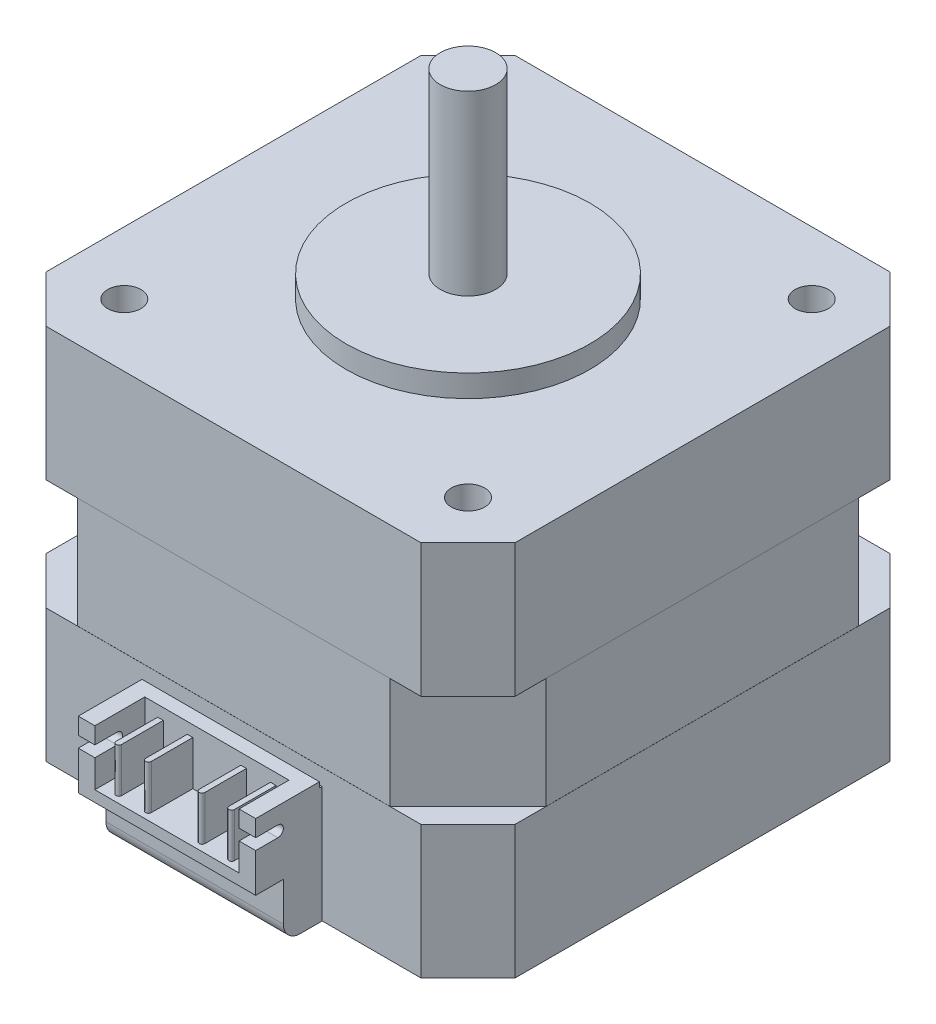
from build123d import *

# Parameters (mm, degrees)
SKETCH1_W               = 42.3
SKETCH1_H               = 42.3
BOSS_EXTRUDE1_DEPTH     = 34
SKETCH2_R               = 11
BOSS_EXTRUDE2_DEPTH     = 2
SKETCH3_R               = 2.5
BOSS_EXTRUDE3_DEPTH     = 16
CUT_EXTRUDE1_DEPTH      = 19
CUT_EXTRUDE1_DEPTH_BACK = 35
SKETCH5_W               = 33.814718626
SKETCH5_H               = 10
CUT_EXTRUDE2_DEPTH      = 0.01
CUT_EXTRUDE3_START      = -12
CUT_EXTRUDE3_DEPTH      = 10
CIRPATTERN1_COUNT       = 4
SKETCH7_R               = 1.5
CUT_EXTRUDE4_DEPTH      = 4.5
SKETCH8_W               = 16
SKETCH8_H               = 11
BOSS_EXTRUDE4_DEPTH     = 6
SKETCH9_W               = 16
SKETCH9_H               = 5
CUT_EXTRUDE5_DEPTH      = 2.5
FILLET1_R               = 1.5
SKETCH10_W              = 13
SKETCH10_H              = 4.5
CUT_EXTRUDE6_DEPTH      = 5
CUT_EXTRUDE7_DEPTH      = 30.15
BOSS_EXTRUDE5_DEPTH     = 4
SKETCH13_W              = 16
SKETCH13_H              = 0.25
CUT_EXTRUDE8_DEPTH      = 0.5
FILLET2_R               = 0.125


with BuildPart() as part:
    # Sketch1 → Boss-Extrude1 (new body)
    with BuildSketch(Plane(origin=(0, 0, 0), x_dir=(1, 0, 0), z_dir=(0, 1, 0))):
        Rectangle(SKETCH1_W, SKETCH1_H)
    extrude(amount=BOSS_EXTRUDE1_DEPTH)

    # Sketch2 → Boss-Extrude2 (add)
    with BuildSketch(Plane(origin=(0, 34, 0), x_dir=(1, 0, 0), z_dir=(0, 1, 0))):
        Circle(SKETCH2_R)
    extrude(amount=BOSS_EXTRUDE2_DEPTH)

    # Sketch3 → Boss-Extrude3 (add)
    with BuildSketch(Plane(origin=(0, 36, 0), x_dir=(1, 0, 0), z_dir=(0, 1, 0))):
        Circle(SKETCH3_R)
    extrude(amount=BOSS_EXTRUDE3_DEPTH)

    # Sketch4 → Cut-Extrude1 (cut, two sides)
    with BuildSketch(Plane(origin=(0, 34, 0), x_dir=(1, 0, 0), z_dir=(0, 1, 0))) as cut_extrude1_sk:
        Polygon((-21.15, 16.907359313), (-16.907359313, 21.15), (-21.15, 21.15), align=None)
        Polygon((21.15, 21.15), (21.15, 16.907359313), (16.907359313, 21.15), align=None)
        Polygon((21.15, -16.907359313), (16.907359313, -21.15), (21.15, -21.15), align=None)
        Polygon((-21.15, -21.15), (-21.15, -16.907359313), (-16.907359313, -21.15), align=None)
    extrude(amount=CUT_EXTRUDE1_DEPTH, mode=Mode.SUBTRACT)
    extrude(cut_extrude1_sk.sketch, amount=-CUT_EXTRUDE1_DEPTH_BACK, mode=Mode.SUBTRACT)

    # Sketch5 → Cut-Extrude2 (cut)
    with BuildSketch(Plane(origin=(21.15, 0, 0), x_dir=(0, 0, -1), z_dir=(1, 0, 0))):
        with Locations((0, 17)):
            Rectangle(SKETCH5_W, SKETCH5_H)
    cut_extrude2 = extrude(amount=-CUT_EXTRUDE2_DEPTH, mode=Mode.SUBTRACT)

    # Sketch6 → Cut-Extrude3 (cut)
    with BuildSketch(Plane(origin=(0, 34, 0), x_dir=(1, 0, 0), z_dir=(0, 1, 0)).offset(CUT_EXTRUDE3_START)):
        Polygon((21.15, 14.078932188), (14.078932188, 21.15), (21.15, 21.15), align=None)
    cut_extrude3 = extrude(amount=-CUT_EXTRUDE3_DEPTH, mode=Mode.SUBTRACT)

    # CirPattern1: Cut-Extrude2, Cut-Extrude3 ×4 about axis
    cirpattern1_axis = Axis((0, 0, 0), (0, 1, 0))
    for i in range(1, CIRPATTERN1_COUNT):
        add(cut_extrude2.rotate(cirpattern1_axis, i * 360 / CIRPATTERN1_COUNT), mode=Mode.SUBTRACT)
        add(cut_extrude3.rotate(cirpattern1_axis, i * 360 / CIRPATTERN1_COUNT), mode=Mode.SUBTRACT)

    # Sketch7 → Cut-Extrude4 (cut)
    with BuildSketch(Plane(origin=(0, 34, 0), x_dir=(1, 0, 0), z_dir=(0, 1, 0))):
        with Locations((15.5, 15.5)):
            Circle(SKETCH7_R)
        with Locations((15.5, -15.5)):
            Circle(SKETCH7_R)
        with Locations((-15.5, -15.5)):
            Circle(SKETCH7_R)
        with Locations((-15.5, 15.5)):
            Circle(SKETCH7_R)
    extrude(amount=-CUT_EXTRUDE4_DEPTH, mode=Mode.SUBTRACT)

    # Sketch8 → Boss-Extrude4 (add)
    with BuildSketch(Plane.XY.offset(21.15)):
        with Locations((0, 5.5)):
            Rectangle(SKETCH8_W, SKETCH8_H)
    extrude(amount=BOSS_EXTRUDE4_DEPTH)

    # Sketch9 → Cut-Extrude5 (cut)
    with BuildSketch(Plane.XY.offset(27.15)):
        with Locations((0, 2.5)):
            Rectangle(SKETCH9_W, SKETCH9_H)
    extrude(amount=-CUT_EXTRUDE5_DEPTH, mode=Mode.SUBTRACT)

    # Fillet1
    fillet1_edges = [part.edges().sort_by_distance(p)[0] for p in [
        (0, 0, 24.65),
    ]]
    fillet(fillet1_edges, radius=FILLET1_R)

    # Sketch10 → Cut-Extrude6 (cut)
    with BuildSketch(Plane(origin=(0, 11, 0), x_dir=(1, 0, 0), z_dir=(0, 1, 0))):
        with Locations((0, -24.9)):
            Rectangle(SKETCH10_W, SKETCH10_H)
    extrude(amount=-CUT_EXTRUDE6_DEPTH, mode=Mode.SUBTRACT)

    # Sketch11 → Cut-Extrude7 (cut, through all)
    with BuildSketch(Plane(origin=(8, 0, 0), x_dir=(0, 0, -1), z_dir=(1, 0, 0))):
        with BuildLine():
            Line((-27.15, 9.5), (-25.15, 9.5))
            ThreePointArc((-25.15, 9.5), (-24.65, 9), (-25.15, 8.5))
            Line((-25.15, 8.5), (-27.15, 8.5))
            Line((-27.15, 8.5), (-27.15, 9.5))
        make_face()
    extrude(amount=-CUT_EXTRUDE7_DEPTH, mode=Mode.SUBTRACT)

    # Sketch12 → Boss-Extrude5 (add)
    with BuildSketch(Plane(origin=(0, 6, 0), x_dir=(1, 0, 0), z_dir=(0, 1, 0))):
        with BuildLine():
            Line((-2.667, -22.65), (-2.167, -22.65))
            Line((-2.167, -22.65), (-2.167, -26.4))
            ThreePointArc((-2.167, -26.4), (-2.417, -26.65), (-2.667, -26.4))
            Line((-2.667, -26.4), (-2.667, -22.65))
        make_face()
        with BuildLine():
            Line((5.334, -22.65), (5.334, -26.4))
            ThreePointArc((5.334, -26.4), (5.084, -26.65), (4.834, -26.4))
            Line((4.834, -26.4), (4.834, -22.65))
            Line((4.834, -22.65), (5.334, -22.65))
        make_face()
        with BuildLine():
            Line((-4.834, -22.65), (-5.334, -22.65))
            Line((-5.334, -22.65), (-5.334, -26.4))
            ThreePointArc((-5.334, -26.4), (-5.084, -26.65), (-4.834, -26.4))
            Line((-4.834, -26.4), (-4.834, -22.65))
        make_face()
        with BuildLine():
            Line((2.167, -22.65), (2.167, -26.4))
            ThreePointArc((2.167, -26.4), (2.417, -26.65), (2.667, -26.4))
            Line((2.667, -26.4), (2.667, -22.65))
            Line((2.667, -22.65), (2.167, -22.65))
        make_face()
    extrude(amount=BOSS_EXTRUDE5_DEPTH)

    # Sketch13 → Cut-Extrude8 (cut)
    with BuildSketch(Plane(origin=(0, 11, 0), x_dir=(1, 0, 0), z_dir=(0, 1, 0))):
        with Locations((0, -21.275)):
            Rectangle(SKETCH13_W, SKETCH13_H)
    extrude(amount=-CUT_EXTRUDE8_DEPTH, mode=Mode.SUBTRACT)

    # Fillet2
    fillet2_edges = [part.edges().sort_by_distance(p)[0] for p in [
        (0, 10.5, 21.4),
    ]]
    fillet(fillet2_edges, radius=FILLET2_R)


solid = part.part
